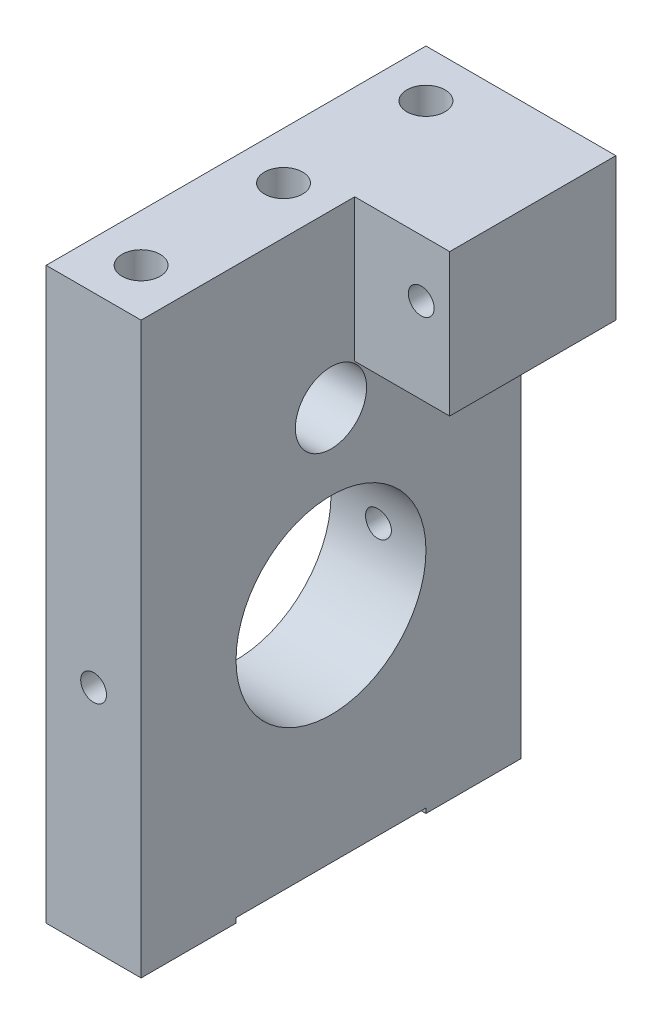
from build123d import *

# Parameters (mm, degrees)
SKETCH1_W                   = 50.8
SKETCH1_H                   = 76.2
BOSS_EXTRUDE1_DEPTH         = 6.35
SKETCH2_W                   = 22.225
SKETCH2_H                   = 19.05
BOSS_EXTRUDE2_DEPTH         = 12.7
F_1_4_20_TAPPED_HOLE1_D     = 5.1054
F_1_4_20_TAPPED_HOLE1_DEPTH = 19.05
F_1_4_20_TAPPED_HOLE1_TIP   = 1.533816902
CUT_EXTRUDE1_REACH          = 14.7
SKETCH5_W                   = 25.4
SKETCH5_H                   = 0.635
F_1_4_20_TAPPED_HOLE2_D     = 5.1054
F_1_4_20_TAPPED_HOLE2_DEPTH = 19.05
F_1_4_20_TAPPED_HOLE2_TIP   = 1.533816902
CUT_EXTRUDE2_REACH          = 14.7
SKETCH8_R                   = 12.7
F_8_32_TAPPED_HOLE1_D       = 3.4544
SKETCH11_R                  = 4.7625
CUT_EXTRUDE3_DEPTH          = 26.4
F_8_32_TAPPED_HOLE2_D       = 3.4544


with BuildPart() as part:
    # Sketch1 → Boss-Extrude1 (new body, symmetric)
    with BuildSketch(Plane(origin=(0, 0, 0), x_dir=(0, 0, -1), z_dir=(1, 0, 0))):
        Rectangle(SKETCH1_W, SKETCH1_H)
    extrude(amount=BOSS_EXTRUDE1_DEPTH, both=True)

    # Sketch2 → Boss-Extrude2 (add)
    with BuildSketch(Plane(origin=(6.35, 0, 0), x_dir=(0, 0, -1), z_dir=(1, 0, 0))):
        with Locations((14.2875, 28.575)):
            Rectangle(SKETCH2_W, SKETCH2_H)
    extrude(amount=BOSS_EXTRUDE2_DEPTH)

    # 1/4-20 Tapped Hole1
    with Locations(Plane(origin=(0, -38.1, 0), x_dir=(-1, 0, 0), z_dir=(0, -1, 0))):
        with Locations((0, -19.05), (0, 19.05)):
            Hole(F_1_4_20_TAPPED_HOLE1_D / 2, depth=F_1_4_20_TAPPED_HOLE1_DEPTH)
            with Locations((0, 0, -(F_1_4_20_TAPPED_HOLE1_DEPTH + F_1_4_20_TAPPED_HOLE1_TIP / 2))):  # 118° drill point
                Cone(0, F_1_4_20_TAPPED_HOLE1_D / 2, F_1_4_20_TAPPED_HOLE1_TIP, mode=Mode.SUBTRACT)

    # Sketch5 → Cut-Extrude1 (cut, up to next)
    with BuildSketch(Plane(origin=(6.35, 0, 0), x_dir=(0, 0, -1), z_dir=(1, 0, 0)), mode=Mode.PRIVATE) as cut_extrude1_sk1:
        with Locations((0, -37.7825)):
            Rectangle(SKETCH5_W, SKETCH5_H)
    cut_extrude1_tool1 = extrude(cut_extrude1_sk1.sketch, amount=-CUT_EXTRUDE1_REACH, mode=Mode.PRIVATE) & part.part
    add(cut_extrude1_tool1.solids().sort_by_distance((6.35, -37.7825, 0))[0], mode=Mode.SUBTRACT)

    # 1/4-20 Tapped Hole2
    with Locations(Plane(origin=(0, 38.1, 0), x_dir=(1, 0, 0), z_dir=(0, 1, 0))):
        with Locations((0, 19.05), (0, 0), (0, -19.05)):
            Hole(F_1_4_20_TAPPED_HOLE2_D / 2, depth=F_1_4_20_TAPPED_HOLE2_DEPTH)
            with Locations((0, 0, -(F_1_4_20_TAPPED_HOLE2_DEPTH + F_1_4_20_TAPPED_HOLE2_TIP / 2))):  # 118° drill point
                Cone(0, F_1_4_20_TAPPED_HOLE2_D / 2, F_1_4_20_TAPPED_HOLE2_TIP, mode=Mode.SUBTRACT)

    # Sketch8 → Cut-Extrude2 (cut, up to next)
    with BuildSketch(Plane(origin=(6.35, 0, 0), x_dir=(0, 0, -1), z_dir=(1, 0, 0)), mode=Mode.PRIVATE) as cut_extrude2_sk1:
        with Locations((0, -7.62)):
            Circle(SKETCH8_R)
    cut_extrude2_tool1 = extrude(cut_extrude2_sk1.sketch, amount=-CUT_EXTRUDE2_REACH, mode=Mode.PRIVATE) & part.part
    add(cut_extrude2_tool1.solids().sort_by_distance((6.35, -7.62, 0))[0], mode=Mode.SUBTRACT)

    # #8-32 Tapped Hole1 (through all)
    with Locations(Plane.XY.offset(-3.175)):
        with Locations((15.24, 30.48)):
            Hole(F_8_32_TAPPED_HOLE1_D / 2)

    # Sketch11 → Cut-Extrude3 (cut, through all)
    with BuildSketch(Plane.ZY.offset(6.35)):
        with Locations((0, 15.24)):
            Circle(SKETCH11_R)
    extrude(amount=-CUT_EXTRUDE3_DEPTH, mode=Mode.SUBTRACT)

    # #8-32 Tapped Hole2 (through all)
    with Locations(Plane.XY.offset(25.4)):
        with Locations((0, -7.62)):
            Hole(F_8_32_TAPPED_HOLE2_D / 2)


solid = part.part
